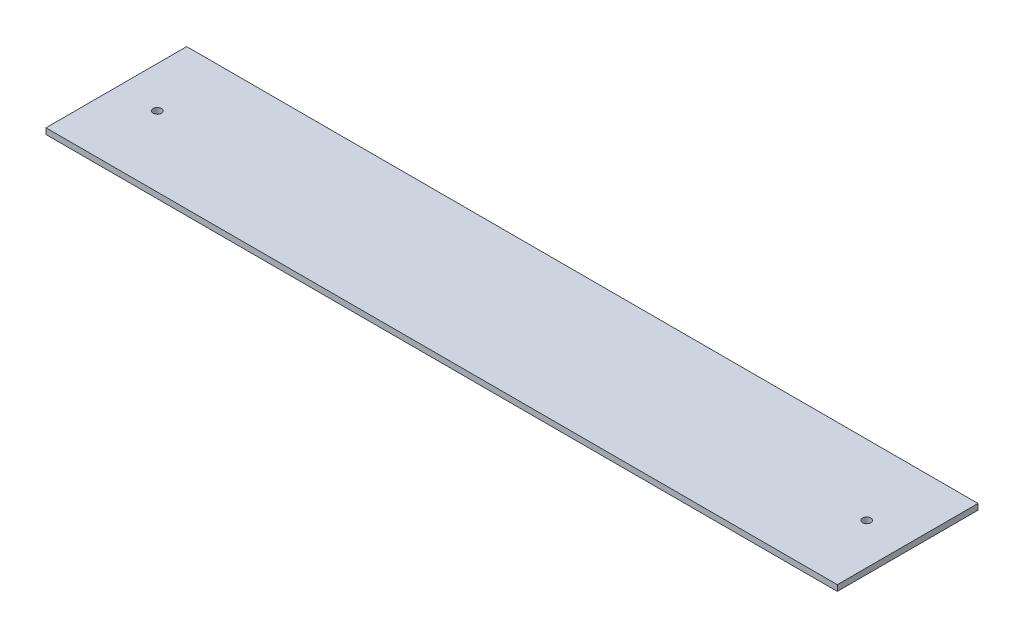
from build123d import *

# Parameters (mm, degrees)
SKETCH1_W           = 428.625
SKETCH1_H           = 76.2
SKETCH1_R           = 2.25
BOSS_EXTRUDE1_DEPTH = 3.175


with BuildPart() as part:
    # Sketch1 → Boss-Extrude1 (new body)
    with BuildSketch(Plane(origin=(0, 0, 0), x_dir=(1, 0, 0), z_dir=(0, 1, 0))):
        Rectangle(SKETCH1_W, SKETCH1_H)
        with Locations((-192.0875, 0)):
            Circle(SKETCH1_R, mode=Mode.SUBTRACT)
        with Locations((192.0875, 0)):
            Circle(SKETCH1_R, mode=Mode.SUBTRACT)
    extrude(amount=-BOSS_EXTRUDE1_DEPTH)


solid = part.part
